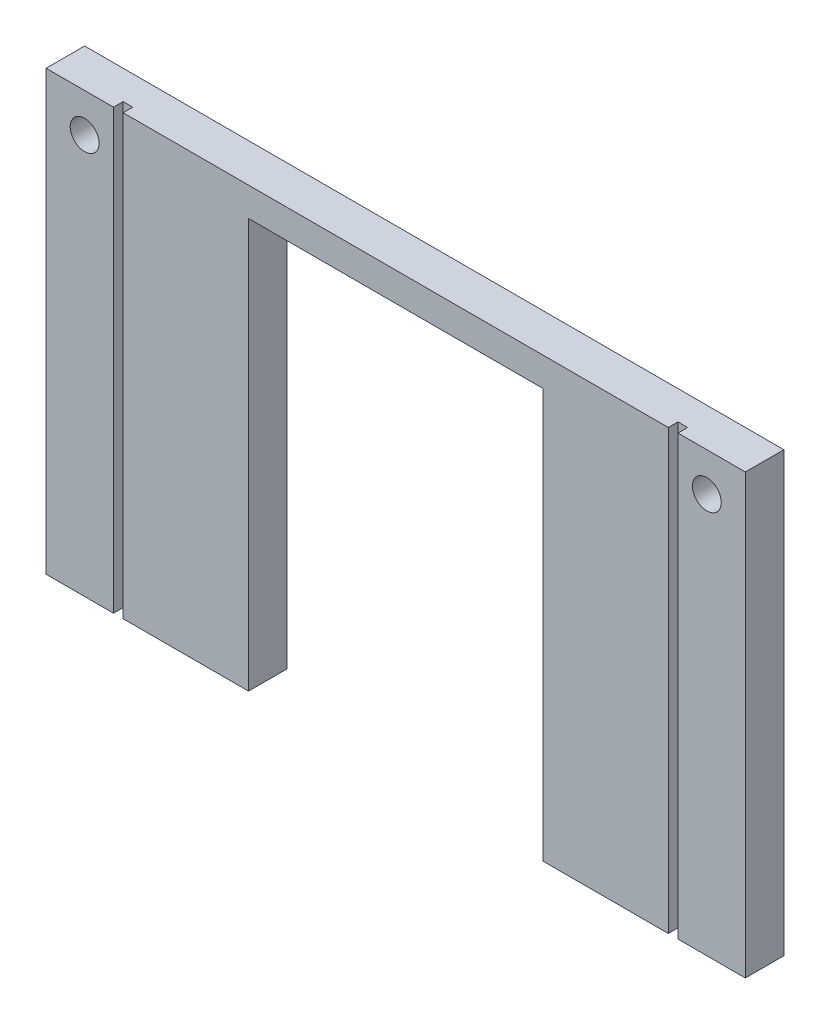
from build123d import *

# Parameters (mm, degrees)
SKETCH1_W           = 72.6
SKETCH1_H           = 45.5
SKETCH1_R           = 1.5
BOSS_EXTRUDE1_DEPTH = 4
SKETCH2_W           = 1
SKETCH2_H           = 45.5
CUT_EXTRUDE1_DEPTH  = 1
SKETCH3_W           = 30.575
SKETCH3_H           = 42.5
CUT_EXTRUDE2_DEPTH  = 4


with BuildPart() as part:
    # Sketch1 → Boss-Extrude1 (new body)
    with BuildSketch(Plane.XY):
        with Locations((36.3, 22.75)):
            Rectangle(SKETCH1_W, SKETCH1_H)
        with Locations((4, 41.5)):
            Circle(SKETCH1_R, mode=Mode.SUBTRACT)
        with Locations((68.6, 41.5)):
            Circle(SKETCH1_R, mode=Mode.SUBTRACT)
    extrude(amount=BOSS_EXTRUDE1_DEPTH)

    # Sketch2 → Cut-Extrude1 (cut)
    with BuildSketch(Plane.XY.offset(4)):
        with Locations((7.5, 22.75)):
            Rectangle(SKETCH2_W, SKETCH2_H)
        with Locations((65.1, 22.75)):
            Rectangle(SKETCH2_W, SKETCH2_H)
    extrude(amount=-CUT_EXTRUDE1_DEPTH, mode=Mode.SUBTRACT)

    # Sketch3 → Cut-Extrude2 (cut)
    with BuildSketch(Plane.XY.offset(4)):
        with Locations((36.3, 21.25)):
            Rectangle(SKETCH3_W, SKETCH3_H)
    extrude(amount=-CUT_EXTRUDE2_DEPTH, mode=Mode.SUBTRACT)


solid = part.part
